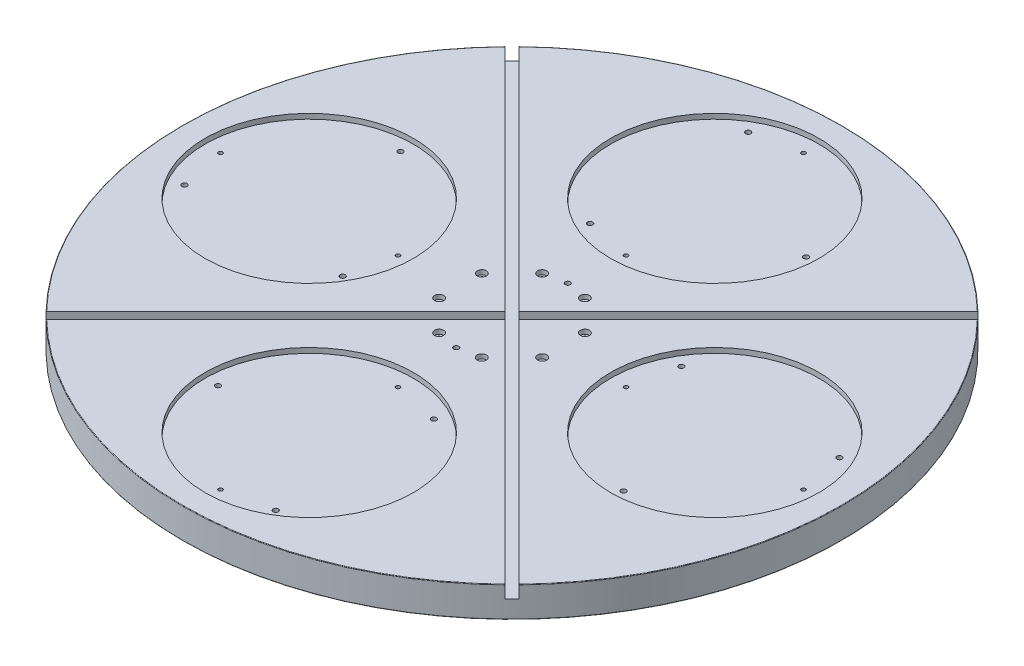
from build123d import *

# Parameters (mm, degrees)
SKETCH1_R                   = 650
BOSS_EXTRUDE1_DEPTH         = 60
SKETCH2_R                   = 205.5
CUT_EXTRUDE1_DEPTH          = 10
SKETCH3_R                   = 4
CUT_EXTRUDE2_DEPTH          = 25
M12_TAPPED_HOLE1_AT_2_COUNT = 2
M12_TAPPED_HOLE1_AT_2_PITCH = 311.769145362
M12_TAPPED_HOLE1_AT_3_COUNT = 2
M12_TAPPED_HOLE1_AT_3_PITCH = 311.769145362
CIRPATTERN1_COUNT           = 4
FILLET1_R                   = 1
SKETCH10_R                  = 5
CUT_EXTRUDE4_DEPTH          = 61
SKETCH11_R                  = 4.5
CUT_EXTRUDE5_DEPTH          = 61
SKETCH12_R                  = 9
CUT_EXTRUDE6_DEPTH          = 8.8
SKETCH14_R                  = 90
CUT_EXTRUDE8_DEPTH          = 7
CUT_EXTRUDE9_DEPTH          = 25


with BuildPart() as part:
    # Sketch1 → Boss-Extrude1 (new body)
    with BuildSketch(Plane(origin=(0, 0, 0), x_dir=(1, 0, 0), z_dir=(0, 1, 0))):
        Circle(SKETCH1_R)
    extrude(amount=-BOSS_EXTRUDE1_DEPTH)

    # Sketch2 → Cut-Extrude1 (cut)
    with BuildSketch(Plane(origin=(0, 0, 0), x_dir=(1, 0, 0), z_dir=(0, 1, 0))):
        with Locations((0, 400)):
            Circle(SKETCH2_R)
        with Locations((400, 0)):
            Circle(SKETCH2_R)
        with Locations((0, -400)):
            Circle(SKETCH2_R)
        with Locations((-400, 0)):
            Circle(SKETCH2_R)
    extrude(amount=-CUT_EXTRUDE1_DEPTH, mode=Mode.SUBTRACT)

    # Sketch3 → Cut-Extrude2 (cut)
    with BuildSketch(Plane(origin=(0, -10, 0), x_dir=(1, 0, 0), z_dir=(0, 1, 0))):
        with Locations((0, 575)):
            Circle(SKETCH3_R)
        with Locations((0, 225)):
            Circle(SKETCH3_R)
    cut_extrude2 = extrude(amount=-CUT_EXTRUDE2_DEPTH, mode=Mode.SUBTRACT)

    # Sketch9 → M12 Tapped Hole1 (revolve, cut)
    with BuildSketch(Plane(origin=(180, -10, -400), x_dir=(0, 0, 1), z_dir=(1, 0, 0))):
        Polygon((0, 0), (0, 29.25), (5.1, 26.185610843), (5.1, 0), align=None)
    m12_tapped_hole1 = revolve(axis=Axis((180, -3.65, -400), (0, -1, 0)), mode=Mode.SUBTRACT)

    # M12 Tapped Hole1 at 2: M12 Tapped Hole1 ×2
    with Locations(*[Vector(-0.866025404, 0, -0.5) * (i * M12_TAPPED_HOLE1_AT_2_PITCH) for i in range(1, M12_TAPPED_HOLE1_AT_2_COUNT)]):
        add(m12_tapped_hole1, mode=Mode.SUBTRACT)

    # M12 Tapped Hole1 at 3: M12 Tapped Hole1 ×2
    with Locations(*[Vector(-0.866025404, 0, 0.5) * (i * M12_TAPPED_HOLE1_AT_3_PITCH) for i in range(1, M12_TAPPED_HOLE1_AT_3_COUNT)]):
        add(m12_tapped_hole1, mode=Mode.SUBTRACT)

    # CirPattern1: M12 Tapped Hole1, Cut-Extrude2 ×4 about axis
    cirpattern1_axis = Axis((0, 0, 0), (0, 1, 0))
    for i in range(1, CIRPATTERN1_COUNT):
        add(m12_tapped_hole1.rotate(cirpattern1_axis, i * 360 / CIRPATTERN1_COUNT), mode=Mode.SUBTRACT)
        add(cut_extrude2.rotate(cirpattern1_axis, i * 360 / CIRPATTERN1_COUNT), mode=Mode.SUBTRACT)

    # CirPattern1 copy 1 sketch → CirPattern1 copy 1 (revolve, cut)
    with BuildSketch(Plane(origin=(-555.884572681, -10, 90), x_dir=(1, 0, 0), z_dir=(0, 0, -1))):
        Polygon((0, 0), (0, 29.25), (5.1, 26.185610843), (5.1, 0), align=None)
    revolve(axis=Axis((-555.884572681, -3.65, 90), (0, -1, 0)), mode=Mode.SUBTRACT)

    # CirPattern1 copy 2 sketch → CirPattern1 copy 2 (revolve, cut)
    with BuildSketch(Plane(origin=(90, -10, 555.884572681), x_dir=(0, 0, -1), z_dir=(-1, 0, 0))):
        Polygon((0, 0), (0, 29.25), (5.1, 26.185610843), (5.1, 0), align=None)
    revolve(axis=Axis((90, -3.65, 555.884572681), (0, -1, 0)), mode=Mode.SUBTRACT)

    # CirPattern1 copy 3 sketch → CirPattern1 copy 3 (revolve, cut)
    with BuildSketch(Plane(origin=(555.884572681, -10, -90), x_dir=(-1, 0, 0), z_dir=(0, 0, 1))):
        Polygon((0, 0), (0, 29.25), (5.1, 26.185610843), (5.1, 0), align=None)
    revolve(axis=Axis((555.884572681, -3.65, -90), (0, -1, 0)), mode=Mode.SUBTRACT)

    # CirPattern1 copy 4 sketch → CirPattern1 copy 4 (revolve, cut)
    with BuildSketch(Plane(origin=(-244.115427319, -10, 90), x_dir=(1, 0, 0), z_dir=(0, 0, -1))):
        Polygon((0, 0), (0, 29.25), (5.1, 26.185610843), (5.1, 0), align=None)
    revolve(axis=Axis((-244.115427319, -3.65, 90), (0, -1, 0)), mode=Mode.SUBTRACT)

    # CirPattern1 copy 5 sketch → CirPattern1 copy 5 (revolve, cut)
    with BuildSketch(Plane(origin=(90, -10, 244.115427319), x_dir=(0, 0, -1), z_dir=(-1, 0, 0))):
        Polygon((0, 0), (0, 29.25), (5.1, 26.185610843), (5.1, 0), align=None)
    revolve(axis=Axis((90, -3.65, 244.115427319), (0, -1, 0)), mode=Mode.SUBTRACT)

    # CirPattern1 copy 6 sketch → CirPattern1 copy 6 (revolve, cut)
    with BuildSketch(Plane(origin=(244.115427319, -10, -90), x_dir=(-1, 0, 0), z_dir=(0, 0, 1))):
        Polygon((0, 0), (0, 29.25), (5.1, 26.185610843), (5.1, 0), align=None)
    revolve(axis=Axis((244.115427319, -3.65, -90), (0, -1, 0)), mode=Mode.SUBTRACT)

    # Fillet1
    fillet1_edges = [part.edges().sort_by_distance(p)[0] for p in [
        (-650, 0, 0),
        (-650, -60, 0),
    ]]
    fillet(fillet1_edges, radius=FILLET1_R)

    # Sketch10 → Cut-Extrude4 (cut, through all)
    with BuildSketch(Plane(origin=(0, 0, 0), x_dir=(1, 0, 0), z_dir=(0, 1, 0))):
        with Locations((0, 110)):
            Circle(SKETCH10_R)
        with Locations((0, -110)):
            Circle(SKETCH10_R)
    extrude(amount=-CUT_EXTRUDE4_DEPTH, mode=Mode.SUBTRACT)

    # Sketch11 → Cut-Extrude5 (cut, through all)
    with BuildSketch(Plane(origin=(0, 0, 0), x_dir=(1, 0, 0), z_dir=(0, 1, 0))):
        with Locations((101.626748576, 42.09517756)):
            Circle(SKETCH11_R)
        with Locations((101.626748576, -42.09517756)):
            Circle(SKETCH11_R)
        with Locations((42.09517756, 101.626748576)):
            Circle(SKETCH11_R)
        with Locations((42.09517756, -101.626748576)):
            Circle(SKETCH11_R)
        with Locations((-42.09517756, 101.626748576)):
            Circle(SKETCH11_R)
        with Locations((-42.09517756, -101.626748576)):
            Circle(SKETCH11_R)
        with Locations((-101.626748576, 42.09517756)):
            Circle(SKETCH11_R)
        with Locations((-101.626748576, -42.09517756)):
            Circle(SKETCH11_R)
    extrude(amount=-CUT_EXTRUDE5_DEPTH, mode=Mode.SUBTRACT)

    # Sketch12 → Cut-Extrude6 (cut)
    with BuildSketch(Plane(origin=(0, 0, 0), x_dir=(1, 0, 0), z_dir=(0, 1, 0))):
        with Locations((-42.09517756, 101.626748576)):
            Circle(SKETCH12_R)
        with Locations((42.09517756, 101.626748576)):
            Circle(SKETCH12_R)
        with Locations((101.626748576, 42.09517756)):
            Circle(SKETCH12_R)
        with Locations((101.626748576, -42.09517756)):
            Circle(SKETCH12_R)
        with Locations((42.09517756, -101.626748576)):
            Circle(SKETCH12_R)
        with Locations((-42.09517756, -101.626748576)):
            Circle(SKETCH12_R)
        with Locations((-101.626748576, -42.09517756)):
            Circle(SKETCH12_R)
        with Locations((-101.626748576, 42.09517756)):
            Circle(SKETCH12_R)
    extrude(amount=-CUT_EXTRUDE6_DEPTH, mode=Mode.SUBTRACT)

    # Sketch14 → Cut-Extrude8 (cut)
    with BuildSketch(Plane.XZ.offset(60)):
        Circle(SKETCH14_R)
    extrude(amount=-CUT_EXTRUDE8_DEPTH, mode=Mode.SUBTRACT)

    # Sketch15 → Cut-Extrude9 (cut)
    with BuildSketch(Plane(origin=(0, 0, 0), x_dir=(1, 0, 0), z_dir=(0, 1, 0))):
        with BuildLine():
            Line((0, -14.142135624), (-7.071067812, -7.071067812))
            Line((-7.071067812, -7.071067812), (-14.142135624, 0))
            Line((-14.142135624, 0), (-465.928888929, -451.786753305))
            ThreePointArc((-465.928888929, -451.786753305), (-458.91230099, -458.91230099), (-451.786753305, -465.928888929))
            Line((-451.786753305, -465.928888929), (0, -14.142135624))
        make_face()
        with BuildLine():
            Line((465.928888929, -451.786753305), (14.142135624, 0))
            Line((14.142135624, 0), (7.071067812, -7.071067812))
            Line((7.071067812, -7.071067812), (0, -14.142135624))
            Line((0, -14.142135624), (451.786753305, -465.928888929))
            ThreePointArc((451.786753305, -465.928888929), (458.91230099, -458.91230099), (465.928888929, -451.786753305))
        make_face()
        with BuildLine():
            Line((0, 14.142135624), (7.071067812, 7.071067812))
            Line((7.071067812, 7.071067812), (14.142135624, 0))
            Line((14.142135624, 0), (465.928888929, 451.786753305))
            ThreePointArc((465.928888929, 451.786753305), (458.91230099, 458.91230099), (451.786753305, 465.928888929))
            Line((451.786753305, 465.928888929), (0, 14.142135624))
        make_face()
        with BuildLine():
            Line((-7.071067812, 7.071067812), (0, 14.142135624))
            Line((0, 14.142135624), (-451.786753305, 465.928888929))
            ThreePointArc((-451.786753305, 465.928888929), (-458.91230099, 458.91230099), (-465.928888929, 451.786753305))
            Line((-465.928888929, 451.786753305), (-14.142135624, 0))
            Line((-14.142135624, 0), (-7.071067812, 7.071067812))
        make_face()
        Polygon((-7.071067812, -7.071067812), (0, 0), (-7.071067812, 7.071067812), (-14.142135624, 0), align=None)
        Polygon((7.071067812, -7.071067812), (0, 0), (-7.071067812, -7.071067812), (0, -14.142135624), align=None)
        Polygon((14.142135624, 0), (7.071067812, 7.071067812), (0, 0), (7.071067812, -7.071067812), align=None)
        Polygon((0, 0), (7.071067812, 7.071067812), (0, 14.142135624), (-7.071067812, 7.071067812), align=None)
        with BuildLine():
            ThreePointArc((-451.786753305, -465.928888929), (-458.91230099, -458.91230099), (-465.928888929, -451.786753305))
            Line((-465.928888929, -451.786753305), (-487.712976159, -473.570840535))
            Line((-487.712976159, -473.570840535), (-473.570840535, -487.712976159))
            Line((-473.570840535, -487.712976159), (-451.786753305, -465.928888929))
        make_face()
        with BuildLine():
            ThreePointArc((-465.928888929, 451.786753305), (-458.91230099, 458.91230099), (-451.786753305, 465.928888929))
            Line((-451.786753305, 465.928888929), (-461.131853897, 475.27398952))
            Line((-461.131853897, 475.27398952), (-475.27398952, 461.131853897))
            Line((-475.27398952, 461.131853897), (-465.928888929, 451.786753305))
        make_face()
        with BuildLine():
            Line((456.45101614, 470.593151764), (451.786753305, 465.928888929))
            ThreePointArc((451.786753305, 465.928888929), (458.91230099, 458.91230099), (465.928888929, 451.786753305))
            Line((465.928888929, 451.786753305), (470.593151764, 456.45101614))
            Line((470.593151764, 456.45101614), (456.45101614, 470.593151764))
        make_face()
        with BuildLine():
            Line((476.238577972, -462.096442349), (465.928888929, -451.786753305))
            ThreePointArc((465.928888929, -451.786753305), (458.91230099, -458.91230099), (451.786753305, -465.928888929))
            Line((451.786753305, -465.928888929), (462.096442349, -476.238577972))
            Line((462.096442349, -476.238577972), (476.238577972, -462.096442349))
        make_face()
    extrude(amount=-CUT_EXTRUDE9_DEPTH, mode=Mode.SUBTRACT)


solid = part.part
